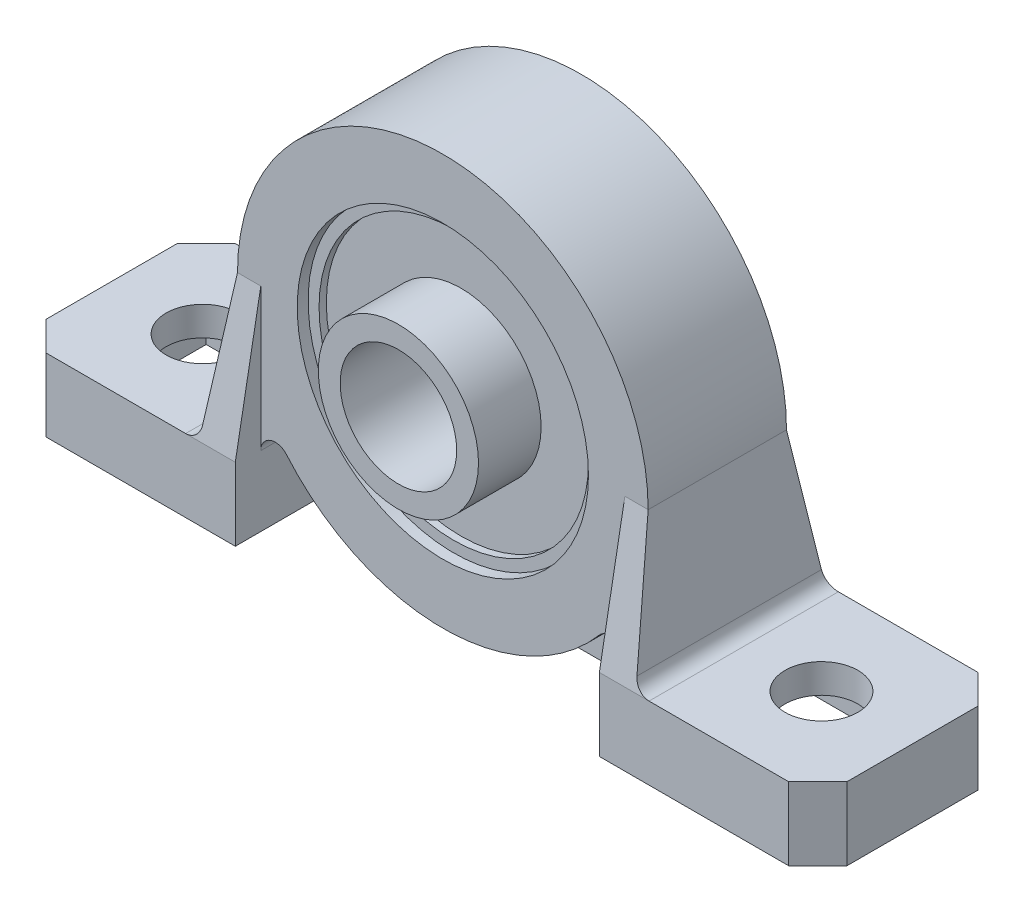
from build123d import *

# Parameters (mm, degrees)
SKETCH1_R           = 10
BOSS_EXTRUDE1_DEPTH = 4
SKETCH2_R           = 9.25
CUT_EXTRUDE2_DEPTH  = 0.5
SKETCH6_R           = 14.1
SKETCH6_R_2         = 10
BOSS_EXTRUDE4_DEPTH = 6.5
SKETCH7_OUTSIDE_W   = 27.678
SKETCH7_OUTSIDE_H   = 43.378
CUT_EXTRUDE6_DEPTH  = 28.5
SKETCH8_R           = 4
CUT_EXTRUDE7_DEPTH  = 7
SKETCH11_W          = 25
SKETCH11_H          = 1.75
CUT_EXTRUDE8_DEPTH  = 29.2
CUT_EXTRUDE9_DEPTH  = 3.5
SKETCH9_R           = 5.5
SKETCH9_R_2         = 4
BOSS_EXTRUDE5_DEPTH = 4.3
SKETCH10_R          = 5.5
SKETCH10_R_2        = 4
BOSS_EXTRUDE6_DEPTH = 1
SKETCH13_W          = 11
SKETCH13_H          = 9
CUT_EXTRUDE10_DEPTH = 3
SKETCH14_R          = 2.5
CUT_EXTRUDE11_DEPTH = 2
CHAMFER1_SIZE       = 2
FILLET1_R           = 1


with BuildPart() as part:
    # Sketch1 → Boss-Extrude1 (new body, symmetric)
    with BuildSketch(Plane.XY):
        Circle(SKETCH1_R)
    extrude(amount=BOSS_EXTRUDE1_DEPTH, both=True)

    # Sketch2 → Cut-Extrude2 (cut)
    with BuildSketch(Plane.XY.offset(4)):
        Circle(SKETCH2_R)
    cut_extrude2 = extrude(amount=-CUT_EXTRUDE2_DEPTH, mode=Mode.SUBTRACT)

    # Mirror1: Cut-Extrude2 across plane
    add(cut_extrude2.mirror(Plane.XY), mode=Mode.SUBTRACT)

    # Sketch6 → Boss-Extrude4 (add, symmetric)
    with BuildSketch(Plane.XY):
        Circle(SKETCH6_R)
        Circle(SKETCH6_R_2, mode=Mode.SUBTRACT)
        with BuildLine():
            ThreePointArc((4.2e-08, -14.1), (-9.9702056, -9.97020563), (-14.1, 0))
            Line((-14.1, 0), (-15, -9.6))
            Line((-15, -9.6), (-27.5, -9.6))
            Line((-27.5, -9.6), (-27.5, -14.6))
            Line((-27.5, -14.6), (-12.5, -14.6))
            Line((-12.5, -14.6), (-12.5, -14.1))
            Line((-12.5, -14.1), (4.2e-08, -14.1))
        make_face()
        with BuildLine():
            Line((15, -9.6), (14.1, 0))
            ThreePointArc((14.1, 0), (9.97020563, -9.9702056), (4.2e-08, -14.1))
            Line((4.2e-08, -14.1), (12.5, -14.1))
            Line((12.5, -14.1), (12.5, -14.6))
            Line((12.5, -14.6), (27.5, -14.6))
            Line((27.5, -14.6), (27.5, -9.6))
            Line((27.5, -9.6), (15, -9.6))
        make_face()
    extrude(amount=BOSS_EXTRUDE4_DEPTH, both=True)

    # Sketch7 outside → Cut-Extrude6 (cut, symmetric)
    with BuildSketch(Plane(origin=(0, 0, 0), x_dir=(0, 0, -1), z_dir=(1, 0, 0))):
        with Locations((0, -0.25)):
            Rectangle(SKETCH7_OUTSIDE_W, SKETCH7_OUTSIDE_H)
        Polygon((-6.5, -9.6), (-4.75, 0), (-4.75, 14.1), (4.75, 14.1), (4.75, 0), (6.5, -9.6), (6.5, -14.6), (-6.5, -14.6), align=None, mode=Mode.SUBTRACT)
    extrude(amount=CUT_EXTRUDE6_DEPTH, both=True, mode=Mode.SUBTRACT)

    # Sketch8 → Cut-Extrude7 (cut)
    with BuildSketch(Plane.XY.offset(3.5)):
        Circle(SKETCH8_R)
    extrude(amount=-CUT_EXTRUDE7_DEPTH, mode=Mode.SUBTRACT)

    # Sketch11 → Cut-Extrude8 (cut, through all)
    with BuildSketch(Plane.XZ.offset(14.1)):
        with Locations((0, 5.625)):
            Rectangle(SKETCH11_W, SKETCH11_H)
        with Locations((0, -5.625)):
            Rectangle(SKETCH11_W, SKETCH11_H)
    extrude(amount=-CUT_EXTRUDE8_DEPTH, mode=Mode.SUBTRACT)

    # Sketch12 → Cut-Extrude9 (cut)
    with BuildSketch(Plane.XY.offset(4.75)):
        with BuildLine():
            ThreePointArc((0, -14.1), (-7.308364514, -12.058101349), (-12.5, -6.523802572))
            Line((-12.5, -6.523802572), (-12.5, -14.1))
            Line((-12.5, -14.1), (0, -14.1))
        make_face()
        with BuildLine():
            ThreePointArc((12.5, -6.523802572), (7.308364514, -12.058101349), (0, -14.1))
            Line((0, -14.1), (12.5, -14.1))
            Line((12.5, -14.1), (12.5, -6.523802572))
        make_face()
    cut_extrude9 = extrude(amount=-CUT_EXTRUDE9_DEPTH, mode=Mode.SUBTRACT)

    # Mirror2: Cut-Extrude9 across plane
    add(cut_extrude9.mirror(Plane.XY), mode=Mode.SUBTRACT)

    # Sketch9 → Boss-Extrude5 (add)
    with BuildSketch(Plane.XY.offset(3.5)):
        Circle(SKETCH9_R)
        Circle(SKETCH9_R_2, mode=Mode.SUBTRACT)
    extrude(amount=BOSS_EXTRUDE5_DEPTH)

    # Sketch10 → Boss-Extrude6 (add)
    with BuildSketch(Plane(origin=(0, 0, -3.5), x_dir=(-1, 0, 0), z_dir=(0, 0, -1))):
        Circle(SKETCH10_R)
        Circle(SKETCH10_R_2, mode=Mode.SUBTRACT)
    extrude(amount=BOSS_EXTRUDE6_DEPTH)

    # Sketch13 → Cut-Extrude10 (cut)
    with BuildSketch(Plane.XZ.offset(14.6)):
        with Locations((-20, 0)):
            Rectangle(SKETCH13_W, SKETCH13_H)
        with Locations((20, 0)):
            Rectangle(SKETCH13_W, SKETCH13_H)
    extrude(amount=-CUT_EXTRUDE10_DEPTH, mode=Mode.SUBTRACT)

    # Sketch14 → Cut-Extrude11 (cut)
    with BuildSketch(Plane.XZ.offset(11.6)):
        with Locations((21.25, 0)):
            Circle(SKETCH14_R)
        with Locations((-21.25, 0)):
            Circle(SKETCH14_R)
    extrude(amount=-CUT_EXTRUDE11_DEPTH, mode=Mode.SUBTRACT)

    # Chamfer1
    chamfer1_edges = [part.edges().sort_by_distance(p)[0] for p in [
        (-27.5, -12.1, -6.5),
        (27.5, -12.1, 6.5),
        (-27.5, -12.1, 6.5),
        (27.5, -12.1, -6.5),
    ]]
    chamfer(chamfer1_edges, length=CHAMFER1_SIZE)

    # Fillet1
    fillet1_edges = [part.edges().sort_by_distance(p)[0] for p in [
        (-15, -9.6, 0),
        (-12.5, -6.523802572, 3),
        (15, -9.6, 0),
        (12.5, -6.523802572, 3),
        (-12.5, -6.523802572, -3),
        (12.5, -6.523802572, -3),
    ]]
    fillet(fillet1_edges, radius=FILLET1_R)


solid = part.part
